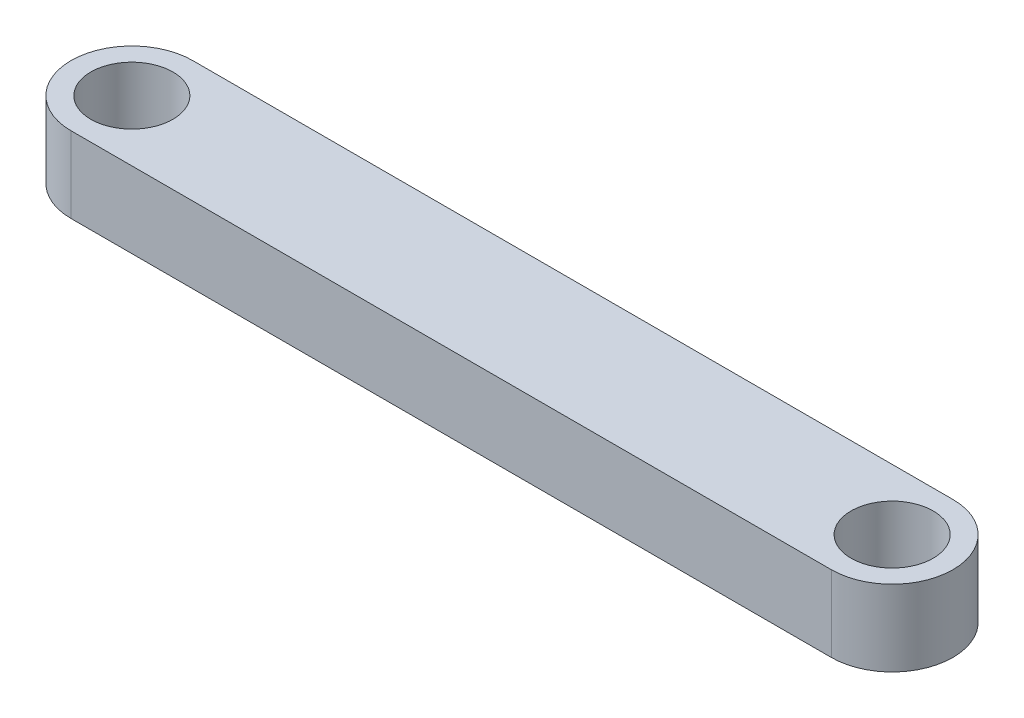
from build123d import *

# Parameters (mm, degrees)
SKETCH1_R           = 2.7
BOSS_EXTRUDE1_DEPTH = 5


with BuildPart() as part:
    # Sketch1 → Boss-Extrude1 (new body)
    with BuildSketch(Plane(origin=(0, 0, 0), x_dir=(1, 0, 0), z_dir=(0, 1, 0))):
        with BuildLine():
            Line((-25, 4), (25, 4))
            ThreePointArc((25, 4), (29, 0), (25, -4))
            Line((25, -4), (-25, -4))
            ThreePointArc((-25, -4), (-29, 0), (-25, 4))
        make_face()
        with Locations((-25, 0)):
            Circle(SKETCH1_R, mode=Mode.SUBTRACT)
        with Locations((25, 0)):
            Circle(SKETCH1_R, mode=Mode.SUBTRACT)
    extrude(amount=BOSS_EXTRUDE1_DEPTH)


solid = part.part
